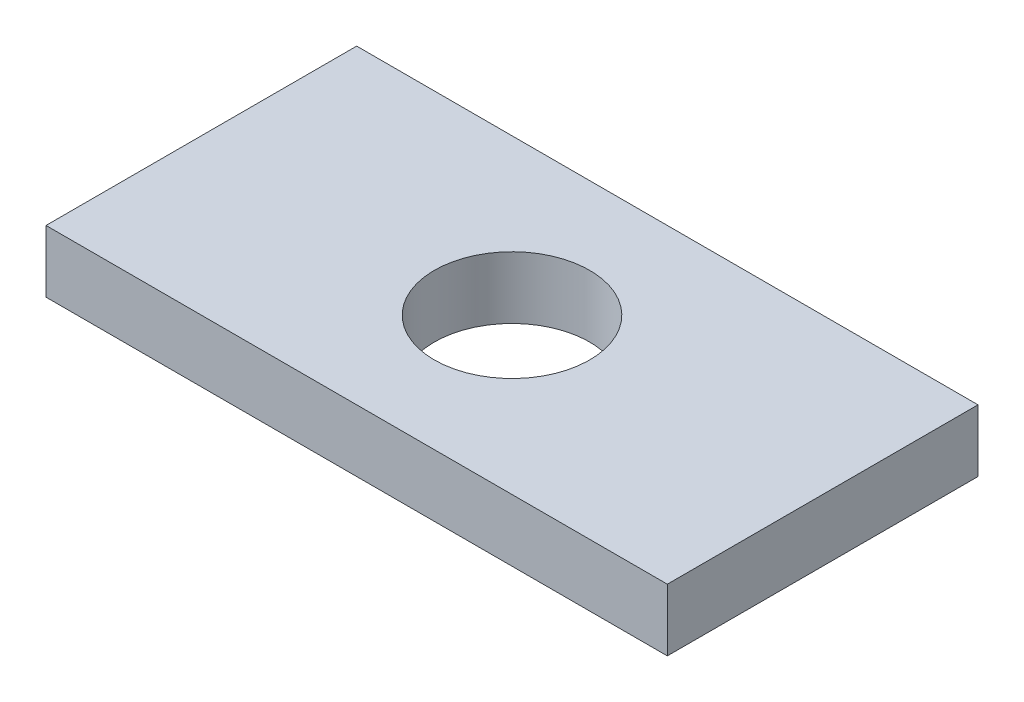
from build123d import *

# Parameters (mm, degrees)
SKETCH_1_W          = 40
SKETCH_1_H          = 20
EXTRUDE_1_DEPTH     = 4
SKETCH_2_R          = 5
CUT_EXTRUDE_1_DEPTH = 5


with BuildPart() as part:
    # Эскиз1 → Бобышка-Вытянуть1 (new body)
    with BuildSketch(Plane(origin=(0, 0, 0), x_dir=(1, 0, 0), z_dir=(0, 1, 0))):
        with Locations((20, 10)):
            Rectangle(SKETCH_1_W, SKETCH_1_H)
    extrude(amount=EXTRUDE_1_DEPTH)

    # Эскиз2 → Вырез-Вытянуть1 (cut, through all)
    with BuildSketch(Plane(origin=(0, 4, 0), x_dir=(1, 0, 0), z_dir=(0, 1, 0))):
        with Locations((20, 10)):
            Circle(SKETCH_2_R)
    extrude(amount=-CUT_EXTRUDE_1_DEPTH, mode=Mode.SUBTRACT)


solid = part.part
